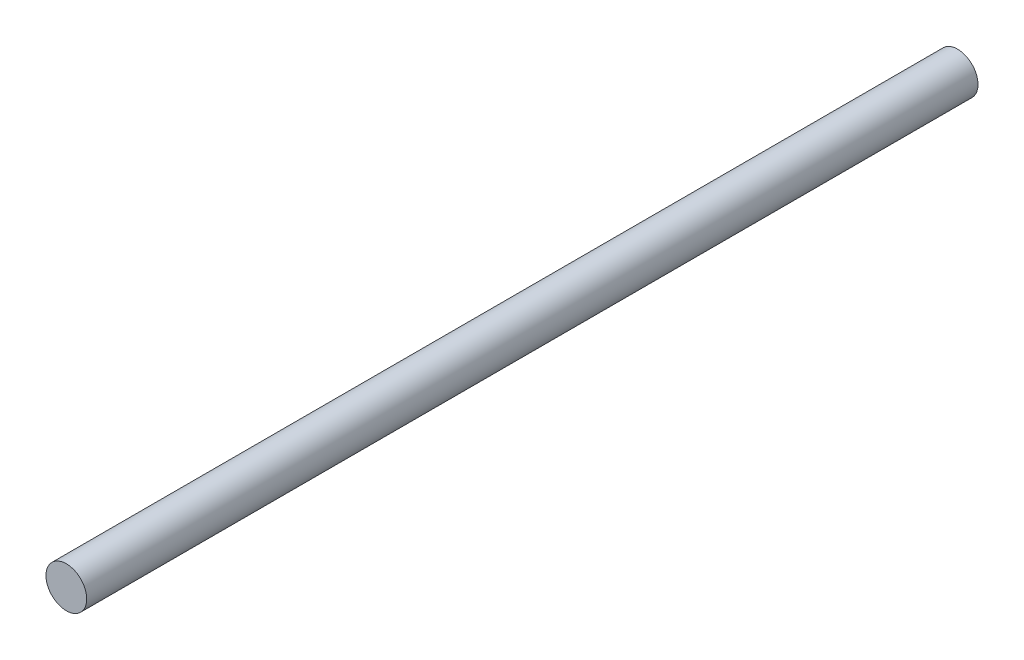
from build123d import *

# Parameters (mm, degrees)
SKETCH1_R           = 4
BOSS_EXTRUDE1_DEPTH = 175


with BuildPart() as part:
    # Sketch1 → Boss-Extrude1 (new body)
    with BuildSketch(Plane.XY):
        Circle(SKETCH1_R)
    extrude(amount=BOSS_EXTRUDE1_DEPTH)


solid = part.part
